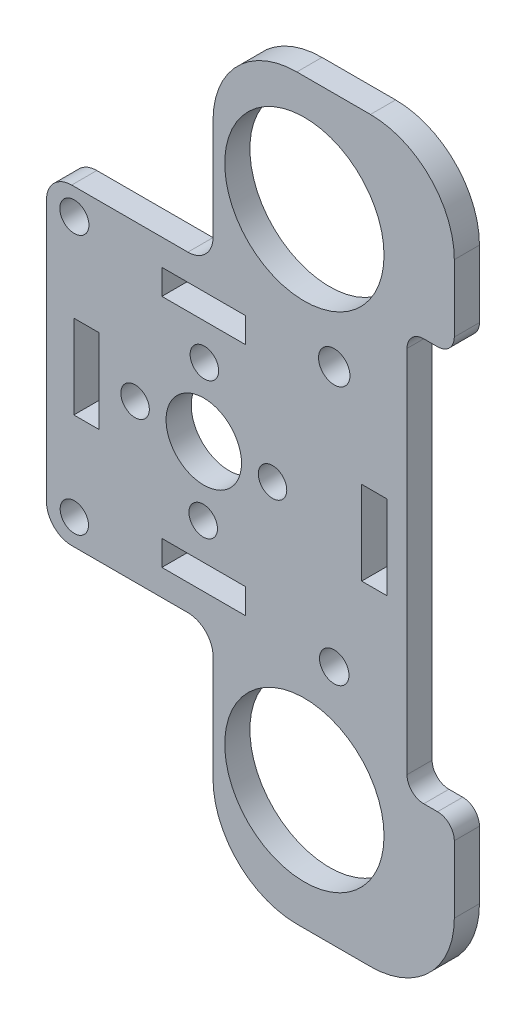
from build123d import *

# Parameters (mm, degrees)
SKETCH1_R           = 1.737885662
SKETCH1_R_2         = 1.873200063
SKETCH1_R_3         = 1.690089146
SKETCH1_R_4         = 1.754205974
SKETCH1_R_5         = 1.7
SKETCH1_R_6         = 4.5
SKETCH1_R_7         = 9.5
SKETCH1_W           = 3
SKETCH1_H           = 10
SKETCH1_W_2         = 10
SKETCH1_H_2         = 3
BOSS_EXTRUDE1_DEPTH = 3
FILLET1_R           = 10
FILLET2_R           = 3
FILLET3_R           = 2


with BuildPart() as part:
    # Sketch1 → Boss-Extrude1 (new body)
    with BuildSketch(Plane.XY):
        Polygon((147.061964125, -92.970138098), (147.061964125, -71.856515964), (147.061964125, -67.856515964), (175.843347401, -67.856515964), (175.843347401, -87.856515964), (170.198907285, -87.856515964), (170.198907285, -135.887076434), (175.843347401, -135.887076434), (175.843347401, -155.887076434), (147.061964125, -155.887076434), (147.061964125, -151.887076434), (147.061964125, -130.215533927), (127.203791419, -130.215533927), (127.203791419, -111.591712302), (127.203791419, -92.970138098), align=None)
        with Locations((130.520049527, -96.082032258)):
            Circle(SKETCH1_R, mode=Mode.SUBTRACT)
        with Locations((161.520049527, -96.082032258)):
            Circle(SKETCH1_R_2, mode=Mode.SUBTRACT)
        with Locations((130.520049527, -127.114221831)):
            Circle(SKETCH1_R_3, mode=Mode.SUBTRACT)
        with Locations((161.520049527, -127.082032258)):
            Circle(SKETCH1_R_4, mode=Mode.SUBTRACT)
        with Locations((154.157584865, -111.662272701)):
            Circle(SKETCH1_R_5, mode=Mode.SUBTRACT)
        with Locations((145.89014032, -119.788596448)):
            Circle(SKETCH1_R_5, mode=Mode.SUBTRACT)
        with Locations((137.763816574, -111.521151903)):
            Circle(SKETCH1_R_5, mode=Mode.SUBTRACT)
        with Locations((146.031261118, -103.394828157)):
            Circle(SKETCH1_R_5, mode=Mode.SUBTRACT)
        with Locations((145.960700719, -111.591712302)):
            Circle(SKETCH1_R_6, mode=Mode.SUBTRACT)
        with Locations((157.960700719, -81.591712302)):
            Circle(SKETCH1_R_7, mode=Mode.SUBTRACT)
        with Locations((157.960700719, -141.591712302)):
            Circle(SKETCH1_R_7, mode=Mode.SUBTRACT)
        with Locations((131.960700719, -111.591712302)):
            Rectangle(SKETCH1_W, SKETCH1_H, mode=Mode.SUBTRACT)
        with Locations((145.960700719, -97.591712302)):
            Rectangle(SKETCH1_W_2, SKETCH1_H_2, mode=Mode.SUBTRACT)
        with Locations((145.960700719, -125.591712302)):
            Rectangle(SKETCH1_W_2, SKETCH1_H_2, mode=Mode.SUBTRACT)
        with Locations((166.293610901, -111.591712302)):
            Rectangle(SKETCH1_W, SKETCH1_H, mode=Mode.SUBTRACT)
    extrude(amount=BOSS_EXTRUDE1_DEPTH)

    # Fillet1
    fillet1_edges = [part.edges().sort_by_distance(p)[0] for p in [
        (147.061964125, -67.856515964, 1.5),
        (175.843347401, -67.856515964, 1.5),
        (175.843347401, -155.887076434, 1.5),
        (147.061964125, -155.887076434, 1.5),
    ]]
    fillet(fillet1_edges, radius=FILLET1_R)

    # Fillet2
    fillet2_edges = [part.edges().sort_by_distance(p)[0] for p in [
        (147.061964125, -130.215533927, 1.5),
        (127.203791419, -130.215533927, 1.5),
        (127.203791419, -92.970138098, 1.5),
        (147.061964125, -92.970138098, 1.5),
    ]]
    fillet(fillet2_edges, radius=FILLET2_R)

    # Fillet3
    fillet3_edges = [part.edges().sort_by_distance(p)[0] for p in [
        (175.843347401, -87.856515964, 1.5),
        (170.198907285, -87.856515964, 1.5),
        (170.198907285, -135.887076434, 1.5),
        (175.843347401, -135.887076434, 1.5),
    ]]
    fillet(fillet3_edges, radius=FILLET3_R)


solid = part.part
